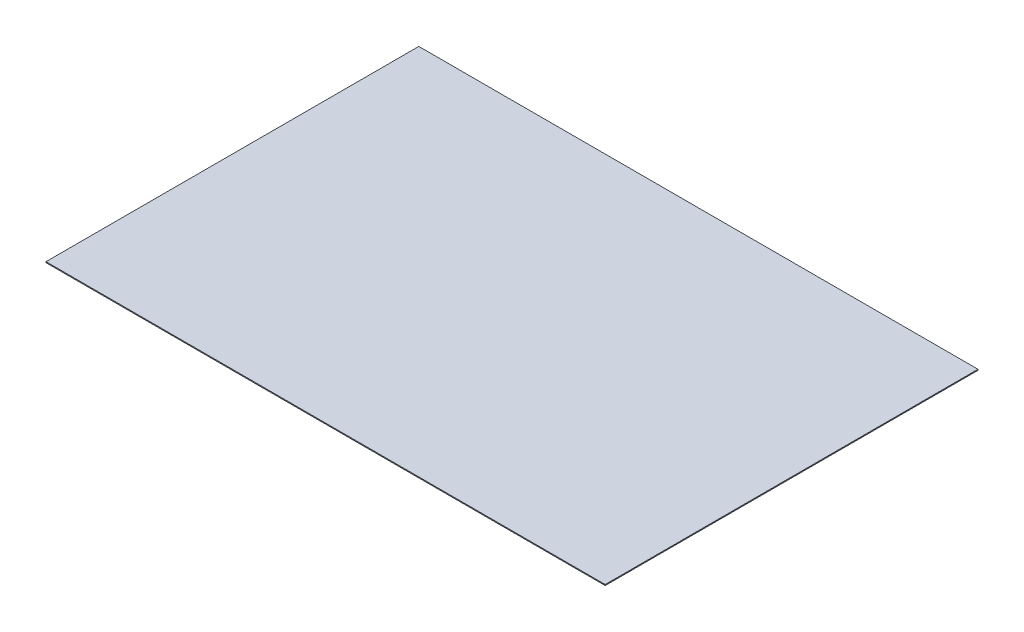
from build123d import *

# Parameters (mm, degrees)
SKETCH3_W           = 457.2
SKETCH3_H           = 0.762
BOSS_EXTRUDE1_DEPTH = 152.4


with BuildPart() as part:
    # Sketch3 → Boss-Extrude1 (new body, symmetric)
    with BuildSketch(Plane.XY):
        Rectangle(SKETCH3_W, SKETCH3_H)
    extrude(amount=BOSS_EXTRUDE1_DEPTH, both=True)


solid = part.part
